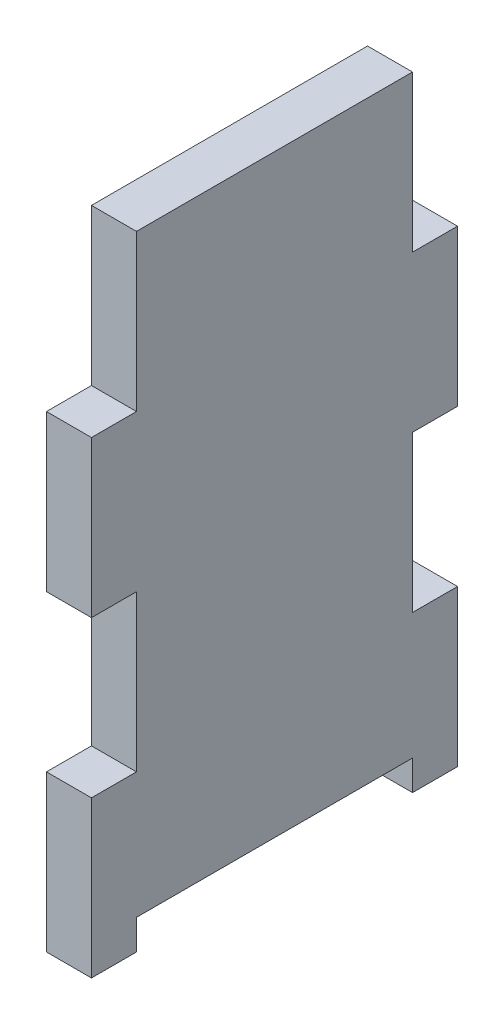
from build123d import *

# Parameters (mm, degrees)
BOSS_EXTRUDE1_DEPTH = 9.525
SKETCH2_W           = 58.42
SKETCH2_H           = 6.35
CUT_EXTRUDE1_DEPTH  = 46.99


with BuildPart() as part:
    # Sketch1 → Boss-Extrude1 (new body)
    with BuildSketch(Plane(origin=(0, 0, 0), x_dir=(0, 0, -1), z_dir=(1, 0, 0))):
        Polygon((9.525, -99.06), (0, -99.06), (0, -132.08), (77.47, -132.08), (77.47, -99.06), (67.945, -99.06), (67.945, -66.04), (77.47, -66.04), (77.47, -33.02), (67.945, -33.02), (67.945, 0), (9.525, 0), (9.525, -33.02), (0, -33.02), (0, -66.04), (9.525, -66.04), align=None)
    extrude(amount=BOSS_EXTRUDE1_DEPTH)

    # Sketch2 → Cut-Extrude1 (cut)
    with BuildSketch(Plane(origin=(9.525, 0, 0), x_dir=(0, 0, -1), z_dir=(1, 0, 0))):
        with Locations((38.735, -128.905)):
            Rectangle(SKETCH2_W, SKETCH2_H)
    extrude(amount=-CUT_EXTRUDE1_DEPTH, mode=Mode.SUBTRACT)


solid = part.part
